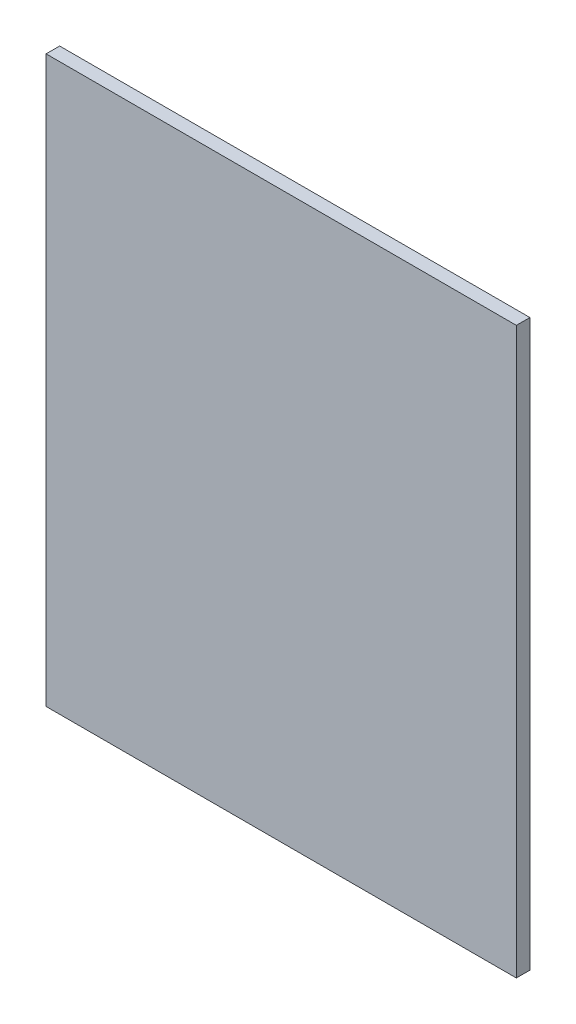
from build123d import *

# Parameters (mm, degrees)
ESQUISSE1_W        = 208
ESQUISSE1_H        = 250
BOSS_EXTRU_1_DEPTH = 6


with BuildPart() as part:
    # Esquisse1 → Boss.-Extru.1 (new body)
    with BuildSketch(Plane.XY):
        with Locations((-16.156874584, 1.186708861)):
            Rectangle(ESQUISSE1_W, ESQUISSE1_H)
    extrude(amount=BOSS_EXTRU_1_DEPTH)


solid = part.part
